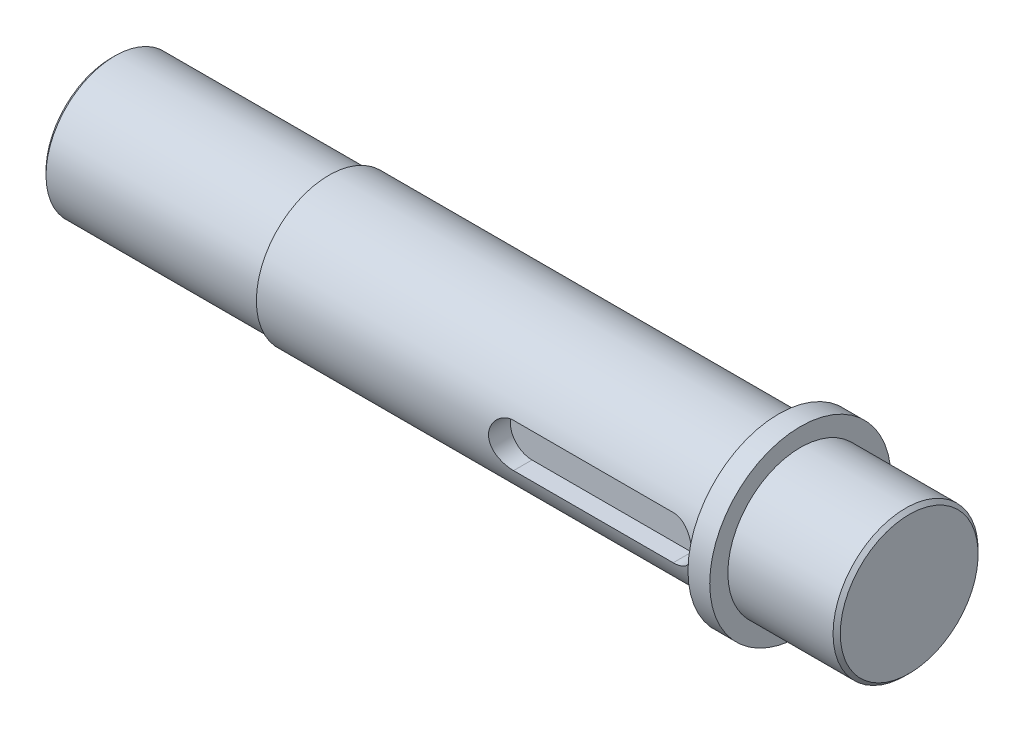
from build123d import *

# Parameters (mm, degrees)
CUT_EXTRUDE_1_DEPTH = 3
CHAMFER_1_SIZE      = 0.5
CHAMFER_2_SIZE      = 0.5


with BuildPart() as part:
    # 草图1 → 旋转1 (revolve)
    with BuildSketch(Plane.XY):
        Polygon((0, 0), (0, 9.5), (30, 9.5), (30, 10), (92, 10), (92, 12.5), (95, 12.5), (95, 10), (110, 10), (110, 0), align=None)
    revolve(axis=Axis((-40.465116279, 0, 0), (1, 0, 0)))

    # 草图3 → 切除-拉伸1 (cut)
    with BuildSketch(Plane.XY.offset(10)):
        with BuildLine():
            Line((65, 3), (87, 3))
            ThreePointArc((87, 3), (90, 0), (87, -3))
            Line((87, -3), (65, -3))
            ThreePointArc((65, -3), (62, 0), (65, 3))
        make_face()
    extrude(amount=-CUT_EXTRUDE_1_DEPTH, mode=Mode.SUBTRACT)

    # 倒角1
    chamfer_1_edges = [part.edges().sort_by_distance(p)[0] for p in [
        (0, -9.5, 0),
    ]]
    chamfer(chamfer_1_edges, length=CHAMFER_1_SIZE)

    # 倒角2
    chamfer_2_edges = [part.edges().sort_by_distance(p)[0] for p in [
        (110, -10, 0),
    ]]
    chamfer(chamfer_2_edges, length=CHAMFER_2_SIZE)


solid = part.part
